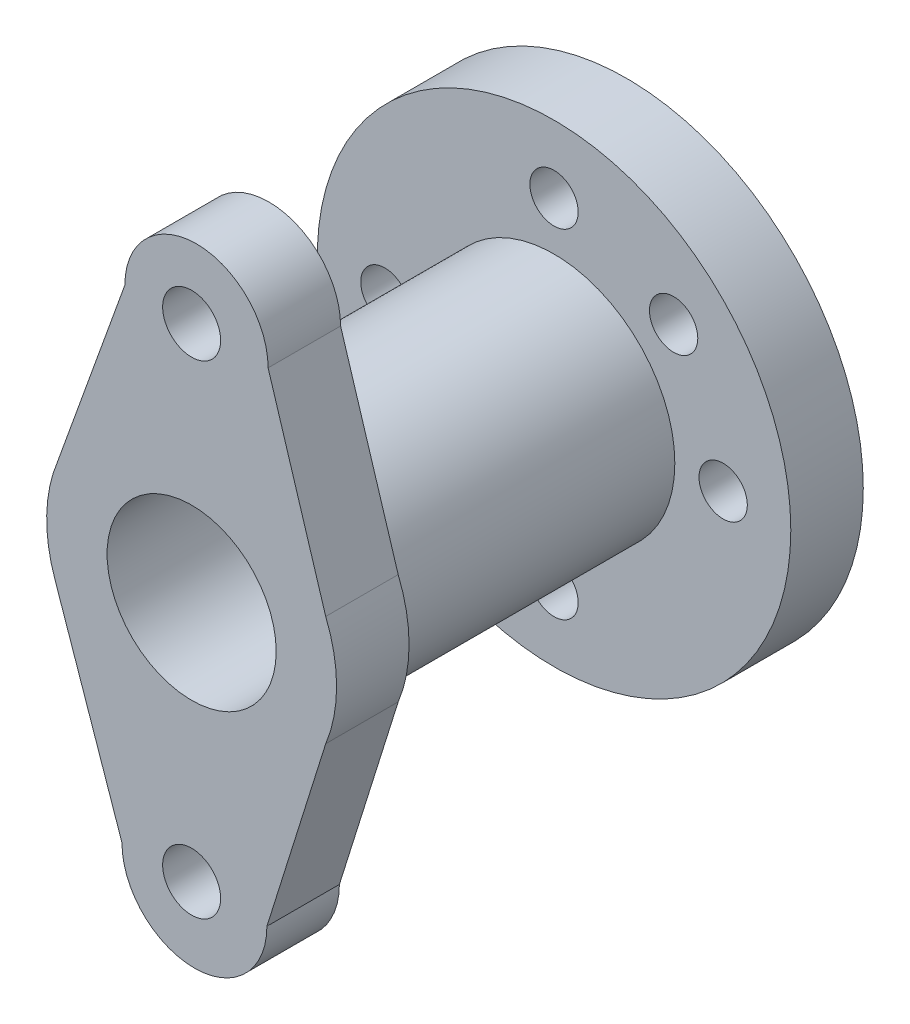
from build123d import *

# Parameters (mm, degrees)
SKETCH1_R           = 49
SKETCH1_R_2         = 5
BOSS_EXTRUDE1_DEPTH = 15
SKETCH2_R           = 25
BOSS_EXTRUDE2_DEPTH = 60
F_3DSKETCH1_R       = 17.5
F_3DSKETCH1_R_2     = 6
BOSS_EXTRUDE3_DEPTH = 15
SKETCH3_R           = 17.5
CUT_EXTRUDE1_DEPTH  = 60


with BuildPart() as part:
    # Sketch1 → Boss-Extrude1 (new body)
    with BuildSketch(Plane.XY):
        with Locations((2.00095732, -3.501675309)):
            Circle(SKETCH1_R)
        with Locations((2.00095732, 31.498324691)):
            Circle(SKETCH1_R_2, mode=Mode.SUBTRACT)
        with Locations((37.00095732, -3.501675309)):
            Circle(SKETCH1_R_2, mode=Mode.SUBTRACT)
        with Locations((2.00095732, -38.501675309)):
            Circle(SKETCH1_R_2, mode=Mode.SUBTRACT)
        with Locations((-32.99904268, -3.501675309)):
            Circle(SKETCH1_R_2, mode=Mode.SUBTRACT)
        with Locations((26.749694661, 21.247062032)):
            Circle(SKETCH1_R_2, mode=Mode.SUBTRACT)
        with Locations((-22.747780022, -28.250412651)):
            Circle(SKETCH1_R_2, mode=Mode.SUBTRACT)
    extrude(amount=BOSS_EXTRUDE1_DEPTH)

    # Sketch2 → Boss-Extrude2 (add)
    with BuildSketch(Plane.XY.offset(15)):
        with Locations((2.00095732, -3.501675309)):
            Circle(SKETCH2_R)
    extrude(amount=BOSS_EXTRUDE2_DEPTH)

    # 3DSketch1 → Boss-Extrude3 (add)
    with BuildSketch(Plane(origin=(17.828624009, 46.498324691, 90), x_dir=(-0.2889903749033983, -0.9573320026057801, 0), z_dir=(0, 0, -1))):
        with BuildLine():
            Line((0, 0), (33.502008681, -22.56364586))
            ThreePointArc((33.502008681, -22.56364586), (43.770932214, -28.017146975), (55.342156817, -29.156544228))
            Line((55.342156817, -29.156544228), (96.002707212, -28.719960078))
            ThreePointArc((96.002707212, -28.719960078), (114.697542875, -18.694835663), (104.672418459, 0))
            Line((104.672418459, 0), (70.251663663, 24.843392205))
            ThreePointArc((70.251663663, 24.843392205), (60.424969024, 29.620810014), (49.539130104, 30.562170435))
            Line((49.539130104, 30.562170435), (8.568124101, 28.383434594))
            ThreePointArc((8.568124101, 28.383434594), (-9.907655246, 18.475779348), (0, 0))
        make_face()
        with Locations(Location((52.440643461, 0.702813104, 0), (0, 0, 253.202479102))):
            Circle(F_3DSKETCH1_R, mode=Mode.SUBTRACT)
        with Locations(Location((100.308395753, -13.747053445, 0), (0, 0, 253.202479102))):
            Circle(F_3DSKETCH1_R_2, mode=Mode.SUBTRACT)
        with Locations(Location((4.571400625, 15.153129604, 0), (0, 0, 253.202479102))):
            Circle(F_3DSKETCH1_R_2, mode=Mode.SUBTRACT)
    extrude(amount=BOSS_EXTRUDE3_DEPTH)

    # Sketch3 → Cut-Extrude1 (cut)
    with BuildSketch(Plane.XY.offset(75)):
        with Locations((2.00095732, -3.501675309)):
            Circle(SKETCH3_R)
    extrude(amount=-CUT_EXTRUDE1_DEPTH, mode=Mode.SUBTRACT)


solid = part.part
